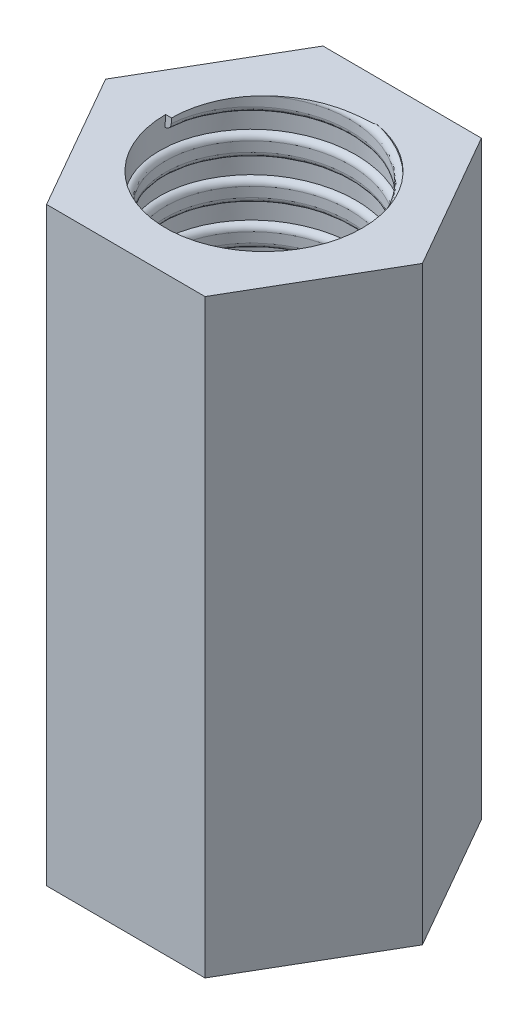
from build123d import *

# Parameters (mm, degrees)
BOSS_EXTRUDE1_DEPTH = 30
SKETCH2_R           = 5
CUT_EXTRUDE1_DEPTH  = 30
SWEEP1_PITCH        = 2
SWEEP1_HEIGHT       = 30
SWEEP1_RADIUS       = 5
SWEEP1_START_ANGLE  = -90
SKETCH7_W           = 47.54314041
SKETCH7_H           = 4.144988526
SKETCH7_W_2         = 46.774707151
SKETCH7_H_2         = 8.246042322
CUT_EXTRUDE2_DEPTH  = 40


with BuildPart() as part:
    # Sketch1 → Boss-Extrude1 (new body)
    with BuildSketch(Plane(origin=(0, 0, 0), x_dir=(1, 0, 0), z_dir=(0, 1, 0))):
        Polygon((-4.015592802, 7.014866199), (-8.082848733, 0.029827722), (-4.067255931, -6.985038477), (4.015592802, -7.014866199), (8.082848733, -0.029827722), (4.067255931, 6.985038477), align=None)
    extrude(amount=BOSS_EXTRUDE1_DEPTH)

    # Sketch2 → Cut-Extrude1 (cut)
    with BuildSketch(Plane(origin=(0, 30, 0), x_dir=(1, 0, 0), z_dir=(0, 1, 0))):
        with Locations(Location((0, 0, 0), (0, 0, 270))):
            Circle(SKETCH2_R)
    extrude(amount=-CUT_EXTRUDE1_DEPTH, mode=Mode.SUBTRACT)

    # Sweep1: sweep along a helix
    with BuildLine() as sweep1_path:
        add(Helix(SWEEP1_PITCH, SWEEP1_HEIGHT, SWEEP1_RADIUS, center=(0, 30, 0), direction=(0, -1, 0), mode=Mode.PRIVATE).rotate(Axis((0, 30, 0), (0, -1, 0)), SWEEP1_START_ANGLE))
    # Sketch4 → Sweep1 (sweep)
    with BuildSketch(Plane(origin=(-5, 30, 0), x_dir=(-1, 0, 0), z_dir=(-1.0648443700362157e-14, -0.0635333619109695, -0.9979797151867816))):
        with BuildLine():
            Line((0.3, 0.25), (0.3, -0.25))
            ThreePointArc((0.3, -0.25), (0, -0.55), (-0.3, -0.25))
            Line((-0.3, -0.25), (-0.3, 0.25))
            ThreePointArc((-0.3, 0.25), (0, 0.55), (0.3, 0.25))
        make_face()
    sweep(path=sweep1_path.line, is_frenet=True)

    # Sketch7 → Cut-Extrude2 (cut)
    with BuildSketch(Plane(origin=(20, 0, 0), x_dir=(0, 0, -1), z_dir=(1, 0, 0))):
        with Locations((-12.408033126, -2.072494263)):
            Rectangle(SKETCH7_W, SKETCH7_H)
        with Locations((14.125846223, 34.123021161)):
            Rectangle(SKETCH7_W_2, SKETCH7_H_2)
    extrude(amount=-CUT_EXTRUDE2_DEPTH, mode=Mode.SUBTRACT)


solid = part.part
